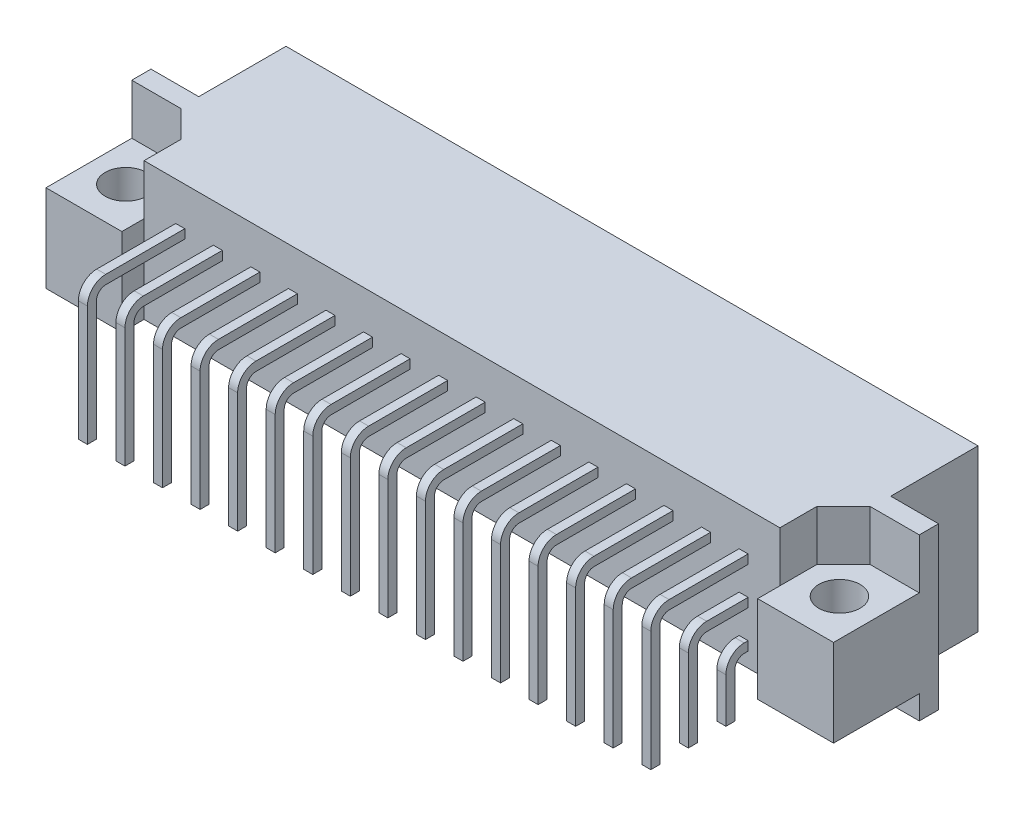
from build123d import *

# Parameters (mm, degrees)
SKETCH_1_W           = 53.26
SKETCH_1_H           = 13
EXTRUDE_1_DEPTH      = 10.9
SKETCH_2_R           = 1.4
CUT_EXTRUDE_1_DEPTH  = 10.9
SKETCH_3_W           = 44.7
SKETCH_3_H           = 8.8
CUT_EXTRUDE_2_DEPTH  = 6.5
SKETCH_5_W           = 0.61
SKETCH_5_H           = 0.61
EXTRUDE_3_DEPTH      = 4.9
SKETCH_4_W           = 0.95
SKETCH_4_H           = 2.8
EXTRUDE_2_DEPTH      = 6.5
SKETCH_6_W           = 3.23
SKETCH_6_H           = 10.9
CUT_EXTRUDE_3_DEPTH  = 5.9
SKETCH_7_W           = 53.26
SKETCH_7_H           = 5.8
CUT_EXTRUDE_4_DEPTH  = 1.6
SKETCH_8_W           = 43
SKETCH_8_H           = 1.5
CUT_EXTRUDE_5_DEPTH  = 11.9
SKETCH_9_R           = 1.4
CUT_EXTRUDE_6_DEPTH  = 3.4
SKETCH_12_W          = 0.61
SKETCH_12_H          = 0.61
EXTRUDE_5_DEPTH      = 1.505
SKETCH_10_W          = 0.61
SKETCH_10_H          = 0.61
EXTRUDE_4_DEPTH      = 1.05
EXTRUDE_4_DEPTH_BACK = 2.61
SKETCH_13_W          = 0.61
SKETCH_13_H          = 0.61
EXTRUDE_6_DEPTH      = 3.145
SKETCH_14_W          = 0.61
SKETCH_14_H          = 0.61
EXTRUDE_7_DEPTH      = 5.685
SKETCH_16_W          = 0.61
SKETCH_16_H          = 0.61
EXTRUDE_8_DEPTH      = 1.93
SKETCH_17_W          = 0.61
SKETCH_17_H          = 0.61
EXTRUDE_9_DEPTH      = 4.5
FILLET_1_R           = 1.24
FILLET_2_R           = 0.64
CHAMFER_1_SIZE       = 0.61


with BuildPart() as part:
    # Эскиз1 → Бобышка-Вытянуть1 (new body)
    with BuildSketch(Plane(origin=(0, 0, 0), x_dir=(1, 0, 0), z_dir=(0, 1, 0))):
        Rectangle(SKETCH_1_W, SKETCH_1_H)
    extrude(amount=EXTRUDE_1_DEPTH)

    # Эскиз2 → Вырез-Вытянуть1 (cut)
    with BuildSketch(Plane(origin=(0, 10.9, 0), x_dir=(1, 0, 0), z_dir=(0, 1, 0))):
        with Locations((24.13, -3.6)):
            Circle(SKETCH_2_R)
        with Locations((-24.13, -3.6)):
            Circle(SKETCH_2_R)
    extrude(amount=-CUT_EXTRUDE_1_DEPTH, mode=Mode.SUBTRACT)

    # Эскиз3 → Вырез-Вытянуть2 (cut)
    with BuildSketch(Plane(origin=(0, 0, -6.5), x_dir=(-1, 0, 0), z_dir=(0, 0, -1))):
        with Locations((0, 5.45)):
            Rectangle(SKETCH_3_W, SKETCH_3_H)
    extrude(amount=-CUT_EXTRUDE_2_DEPTH, mode=Mode.SUBTRACT)

    # Эскиз5 → Бобышка-Вытянуть3 (add)
    with BuildSketch(Plane(origin=(0, 0, 0), x_dir=(-1, 0, 0), z_dir=(0, 0, -1))):
        with Locations((-16.51, 7.99)):
            Rectangle(SKETCH_5_W, SKETCH_5_H)
        with Locations((-19.05, 7.99)):
            Rectangle(SKETCH_5_W, SKETCH_5_H)
        with Locations((-13.97, 7.99)):
            Rectangle(SKETCH_5_W, SKETCH_5_H)
        with Locations((-11.43, 7.99)):
            Rectangle(SKETCH_5_W, SKETCH_5_H)
        with Locations((-8.89, 7.99)):
            Rectangle(SKETCH_5_W, SKETCH_5_H)
        with Locations((-6.35, 7.99)):
            Rectangle(SKETCH_5_W, SKETCH_5_H)
        with Locations((-3.81, 7.99)):
            Rectangle(SKETCH_5_W, SKETCH_5_H)
        with Locations((-1.27, 7.99)):
            Rectangle(SKETCH_5_W, SKETCH_5_H)
        with Locations((1.27, 7.99)):
            Rectangle(SKETCH_5_W, SKETCH_5_H)
        with Locations((3.81, 7.99)):
            Rectangle(SKETCH_5_W, SKETCH_5_H)
        with Locations((6.35, 7.99)):
            Rectangle(SKETCH_5_W, SKETCH_5_H)
        with Locations((8.89, 7.99)):
            Rectangle(SKETCH_5_W, SKETCH_5_H)
        with Locations((11.43, 7.99)):
            Rectangle(SKETCH_5_W, SKETCH_5_H)
        with Locations((13.97, 7.99)):
            Rectangle(SKETCH_5_W, SKETCH_5_H)
        with Locations((16.51, 7.99)):
            Rectangle(SKETCH_5_W, SKETCH_5_H)
        with Locations((19.05, 7.99)):
            Rectangle(SKETCH_5_W, SKETCH_5_H)
        with Locations((-16.51, 5.45)):
            Rectangle(SKETCH_5_W, SKETCH_5_H)
        with Locations((-13.97, 5.45)):
            Rectangle(SKETCH_5_W, SKETCH_5_H)
        with Locations((-11.43, 5.45)):
            Rectangle(SKETCH_5_W, SKETCH_5_H)
        with Locations((-8.89, 5.45)):
            Rectangle(SKETCH_5_W, SKETCH_5_H)
        with Locations((-6.35, 5.45)):
            Rectangle(SKETCH_5_W, SKETCH_5_H)
        with Locations((-3.81, 5.45)):
            Rectangle(SKETCH_5_W, SKETCH_5_H)
        with Locations((-1.27, 5.45)):
            Rectangle(SKETCH_5_W, SKETCH_5_H)
        with Locations((1.27, 5.45)):
            Rectangle(SKETCH_5_W, SKETCH_5_H)
        with Locations((3.81, 5.45)):
            Rectangle(SKETCH_5_W, SKETCH_5_H)
        with Locations((6.35, 5.45)):
            Rectangle(SKETCH_5_W, SKETCH_5_H)
        with Locations((8.89, 5.45)):
            Rectangle(SKETCH_5_W, SKETCH_5_H)
        with Locations((11.43, 5.45)):
            Rectangle(SKETCH_5_W, SKETCH_5_H)
        with Locations((13.97, 5.45)):
            Rectangle(SKETCH_5_W, SKETCH_5_H)
        with Locations((16.51, 5.45)):
            Rectangle(SKETCH_5_W, SKETCH_5_H)
        with Locations((19.05, 5.45)):
            Rectangle(SKETCH_5_W, SKETCH_5_H)
        with Locations((-16.51, 2.91)):
            Rectangle(SKETCH_5_W, SKETCH_5_H)
        with Locations((-13.97, 2.91)):
            Rectangle(SKETCH_5_W, SKETCH_5_H)
        with Locations((-11.43, 2.91)):
            Rectangle(SKETCH_5_W, SKETCH_5_H)
        with Locations((-8.89, 2.91)):
            Rectangle(SKETCH_5_W, SKETCH_5_H)
        with Locations((-6.35, 2.91)):
            Rectangle(SKETCH_5_W, SKETCH_5_H)
        with Locations((-3.81, 2.91)):
            Rectangle(SKETCH_5_W, SKETCH_5_H)
        with Locations((-1.27, 2.91)):
            Rectangle(SKETCH_5_W, SKETCH_5_H)
        with Locations((1.27, 2.91)):
            Rectangle(SKETCH_5_W, SKETCH_5_H)
        with Locations((3.81, 2.91)):
            Rectangle(SKETCH_5_W, SKETCH_5_H)
        with Locations((6.35, 2.91)):
            Rectangle(SKETCH_5_W, SKETCH_5_H)
        with Locations((8.89, 2.91)):
            Rectangle(SKETCH_5_W, SKETCH_5_H)
        with Locations((11.43, 2.91)):
            Rectangle(SKETCH_5_W, SKETCH_5_H)
        with Locations((13.97, 2.91)):
            Rectangle(SKETCH_5_W, SKETCH_5_H)
        with Locations((16.51, 2.91)):
            Rectangle(SKETCH_5_W, SKETCH_5_H)
        with Locations((19.05, 2.91)):
            Rectangle(SKETCH_5_W, SKETCH_5_H)
        with Locations((-19.05, 5.45)):
            Rectangle(SKETCH_5_W, SKETCH_5_H)
        with Locations((-19.05, 2.91)):
            Rectangle(SKETCH_5_W, SKETCH_5_H)
    extrude(amount=EXTRUDE_3_DEPTH)

    # Эскиз4 → Бобышка-Вытянуть2 (add)
    with BuildSketch(Plane(origin=(0, 0, 0), x_dir=(-1, 0, 0), z_dir=(0, 0, -1))):
        with Locations((21.875, 8.45)):
            Rectangle(SKETCH_4_W, SKETCH_4_H)
        with Locations((-21.875, 8.45)):
            Rectangle(SKETCH_4_W, SKETCH_4_H)
    extrude(amount=EXTRUDE_2_DEPTH)

    # Эскиз6 → Вырез-Вытянуть3 (cut)
    with BuildSketch(Plane(origin=(0, 0, -6.5), x_dir=(-1, 0, 0), z_dir=(0, 0, -1))):
        with Locations((25.015, 5.45)):
            Rectangle(SKETCH_6_W, SKETCH_6_H)
        with Locations((-25.015, 5.45)):
            Rectangle(SKETCH_6_W, SKETCH_6_H)
    extrude(amount=-CUT_EXTRUDE_3_DEPTH, mode=Mode.SUBTRACT)

    # Эскиз7 → Вырез-Вытянуть4 (cut)
    with BuildSketch(Plane.XZ):
        with Locations((0, 3.6)):
            Rectangle(SKETCH_7_W, SKETCH_7_H)
    extrude(amount=-CUT_EXTRUDE_4_DEPTH, mode=Mode.SUBTRACT)

    # Эскиз8 → Вырез-Вытянуть5 (cut, through all)
    with BuildSketch(Plane(origin=(0, 10.9, 0), x_dir=(1, 0, 0), z_dir=(0, 1, 0))):
        with Locations((0, -5.75)):
            Rectangle(SKETCH_8_W, SKETCH_8_H)
    extrude(amount=-CUT_EXTRUDE_5_DEPTH, mode=Mode.SUBTRACT)

    # Эскиз9 → Вырез-Вытянуть6 (cut)
    with BuildSketch(Plane(origin=(0, 10.9, 0), x_dir=(1, 0, 0), z_dir=(0, 1, 0))):
        Polygon((-21.5, -2.5), (-23.3, -0.7), (-26.63, -0.7), (-26.63, -6.5), (-21.5, -6.5), (-21.5, -5), align=None)
        with Locations((-24.13, -3.6)):
            Circle(SKETCH_9_R, mode=Mode.SUBTRACT)
        Polygon((21.5, -6.5), (26.63, -6.5), (26.63, -0.7), (23.3, -0.7), (21.5, -2.5), (21.5, -5), align=None)
        with Locations((24.13, -3.6)):
            Circle(SKETCH_9_R, mode=Mode.SUBTRACT)
    extrude(amount=-CUT_EXTRUDE_6_DEPTH, mode=Mode.SUBTRACT)

    # Эскиз12 → Бобышка-Вытянуть5 (add)
    with BuildSketch(Plane.XY.offset(5)):
        with Locations((-16.51, 7.99)):
            Rectangle(SKETCH_12_W, SKETCH_12_H)
        with Locations((-19.05, 7.99)):
            Rectangle(SKETCH_12_W, SKETCH_12_H)
        with Locations((-13.97, 7.99)):
            Rectangle(SKETCH_12_W, SKETCH_12_H)
        with Locations((-11.43, 7.99)):
            Rectangle(SKETCH_12_W, SKETCH_12_H)
        with Locations((-8.89, 7.99)):
            Rectangle(SKETCH_12_W, SKETCH_12_H)
        with Locations((-6.35, 7.99)):
            Rectangle(SKETCH_12_W, SKETCH_12_H)
        with Locations((-3.81, 7.99)):
            Rectangle(SKETCH_12_W, SKETCH_12_H)
        with Locations((-1.27, 7.99)):
            Rectangle(SKETCH_12_W, SKETCH_12_H)
        with Locations((1.27, 7.99)):
            Rectangle(SKETCH_12_W, SKETCH_12_H)
        with Locations((3.81, 7.99)):
            Rectangle(SKETCH_12_W, SKETCH_12_H)
        with Locations((6.35, 7.99)):
            Rectangle(SKETCH_12_W, SKETCH_12_H)
        with Locations((8.89, 7.99)):
            Rectangle(SKETCH_12_W, SKETCH_12_H)
        with Locations((11.43, 7.99)):
            Rectangle(SKETCH_12_W, SKETCH_12_H)
        with Locations((13.97, 7.99)):
            Rectangle(SKETCH_12_W, SKETCH_12_H)
        with Locations((16.51, 7.99)):
            Rectangle(SKETCH_12_W, SKETCH_12_H)
        with Locations((19.05, 7.99)):
            Rectangle(SKETCH_12_W, SKETCH_12_H)
        with Locations((-16.51, 5.45)):
            Rectangle(SKETCH_12_W, SKETCH_12_H)
        with Locations((-13.97, 5.45)):
            Rectangle(SKETCH_12_W, SKETCH_12_H)
        with Locations((-11.43, 5.45)):
            Rectangle(SKETCH_12_W, SKETCH_12_H)
        with Locations((-8.89, 5.45)):
            Rectangle(SKETCH_12_W, SKETCH_12_H)
        with Locations((-6.35, 5.45)):
            Rectangle(SKETCH_12_W, SKETCH_12_H)
        with Locations((-3.81, 5.45)):
            Rectangle(SKETCH_12_W, SKETCH_12_H)
        with Locations((-1.27, 5.45)):
            Rectangle(SKETCH_12_W, SKETCH_12_H)
        with Locations((1.27, 5.45)):
            Rectangle(SKETCH_12_W, SKETCH_12_H)
        with Locations((3.81, 5.45)):
            Rectangle(SKETCH_12_W, SKETCH_12_H)
        with Locations((6.35, 5.45)):
            Rectangle(SKETCH_12_W, SKETCH_12_H)
        with Locations((8.89, 5.45)):
            Rectangle(SKETCH_12_W, SKETCH_12_H)
        with Locations((11.43, 5.45)):
            Rectangle(SKETCH_12_W, SKETCH_12_H)
        with Locations((13.97, 5.45)):
            Rectangle(SKETCH_12_W, SKETCH_12_H)
        with Locations((16.51, 5.45)):
            Rectangle(SKETCH_12_W, SKETCH_12_H)
        with Locations((19.05, 5.45)):
            Rectangle(SKETCH_12_W, SKETCH_12_H)
        with Locations((-16.51, 2.91)):
            Rectangle(SKETCH_12_W, SKETCH_12_H)
        with Locations((-13.97, 2.91)):
            Rectangle(SKETCH_12_W, SKETCH_12_H)
        with Locations((-11.43, 2.91)):
            Rectangle(SKETCH_12_W, SKETCH_12_H)
        with Locations((-8.89, 2.91)):
            Rectangle(SKETCH_12_W, SKETCH_12_H)
        with Locations((-6.35, 2.91)):
            Rectangle(SKETCH_12_W, SKETCH_12_H)
        with Locations((-3.81, 2.91)):
            Rectangle(SKETCH_12_W, SKETCH_12_H)
        with Locations((-1.27, 2.91)):
            Rectangle(SKETCH_12_W, SKETCH_12_H)
        with Locations((1.27, 2.91)):
            Rectangle(SKETCH_12_W, SKETCH_12_H)
        with Locations((3.81, 2.91)):
            Rectangle(SKETCH_12_W, SKETCH_12_H)
        with Locations((6.35, 2.91)):
            Rectangle(SKETCH_12_W, SKETCH_12_H)
        with Locations((8.89, 2.91)):
            Rectangle(SKETCH_12_W, SKETCH_12_H)
        with Locations((11.43, 2.91)):
            Rectangle(SKETCH_12_W, SKETCH_12_H)
        with Locations((13.97, 2.91)):
            Rectangle(SKETCH_12_W, SKETCH_12_H)
        with Locations((16.51, 2.91)):
            Rectangle(SKETCH_12_W, SKETCH_12_H)
        with Locations((19.05, 2.91)):
            Rectangle(SKETCH_12_W, SKETCH_12_H)
        with Locations((-19.05, 5.45)):
            Rectangle(SKETCH_12_W, SKETCH_12_H)
        with Locations((-19.05, 2.91)):
            Rectangle(SKETCH_12_W, SKETCH_12_H)
    extrude(amount=EXTRUDE_5_DEPTH)

    # Эскиз10 → Бобышка-Вытянуть4 (add, two sides)
    with BuildSketch(Plane.XZ) as extrude_4_sk:
        with Locations((-16.51, 6.2)):
            Rectangle(SKETCH_10_W, SKETCH_10_H)
        with Locations((-19.05, 6.2)):
            Rectangle(SKETCH_10_W, SKETCH_10_H)
        with Locations((-13.97, 6.2)):
            Rectangle(SKETCH_10_W, SKETCH_10_H)
        with Locations((-11.43, 6.2)):
            Rectangle(SKETCH_10_W, SKETCH_10_H)
        with Locations((-8.89, 6.2)):
            Rectangle(SKETCH_10_W, SKETCH_10_H)
        with Locations((-6.35, 6.2)):
            Rectangle(SKETCH_10_W, SKETCH_10_H)
        with Locations((-3.81, 6.2)):
            Rectangle(SKETCH_10_W, SKETCH_10_H)
        with Locations((-1.27, 6.2)):
            Rectangle(SKETCH_10_W, SKETCH_10_H)
        with Locations((1.27, 6.2)):
            Rectangle(SKETCH_10_W, SKETCH_10_H)
        with Locations((3.81, 6.2)):
            Rectangle(SKETCH_10_W, SKETCH_10_H)
        with Locations((6.35, 6.2)):
            Rectangle(SKETCH_10_W, SKETCH_10_H)
        with Locations((8.89, 6.2)):
            Rectangle(SKETCH_10_W, SKETCH_10_H)
        with Locations((11.43, 6.2)):
            Rectangle(SKETCH_10_W, SKETCH_10_H)
        with Locations((13.97, 6.2)):
            Rectangle(SKETCH_10_W, SKETCH_10_H)
        with Locations((16.51, 6.2)):
            Rectangle(SKETCH_10_W, SKETCH_10_H)
        with Locations((19.05, 6.2)):
            Rectangle(SKETCH_10_W, SKETCH_10_H)
        with Locations((-16.51, 8.74)):
            Rectangle(SKETCH_10_W, SKETCH_10_H)
        with Locations((-13.97, 8.74)):
            Rectangle(SKETCH_10_W, SKETCH_10_H)
        with Locations((-11.43, 8.74)):
            Rectangle(SKETCH_10_W, SKETCH_10_H)
        with Locations((-8.89, 8.74)):
            Rectangle(SKETCH_10_W, SKETCH_10_H)
        with Locations((-6.35, 8.74)):
            Rectangle(SKETCH_10_W, SKETCH_10_H)
        with Locations((-3.81, 8.74)):
            Rectangle(SKETCH_10_W, SKETCH_10_H)
        with Locations((-1.27, 8.74)):
            Rectangle(SKETCH_10_W, SKETCH_10_H)
        with Locations((1.27, 8.74)):
            Rectangle(SKETCH_10_W, SKETCH_10_H)
        with Locations((3.81, 8.74)):
            Rectangle(SKETCH_10_W, SKETCH_10_H)
        with Locations((6.35, 8.74)):
            Rectangle(SKETCH_10_W, SKETCH_10_H)
        with Locations((8.89, 8.74)):
            Rectangle(SKETCH_10_W, SKETCH_10_H)
        with Locations((11.43, 8.74)):
            Rectangle(SKETCH_10_W, SKETCH_10_H)
        with Locations((13.97, 8.74)):
            Rectangle(SKETCH_10_W, SKETCH_10_H)
        with Locations((16.51, 8.74)):
            Rectangle(SKETCH_10_W, SKETCH_10_H)
        with Locations((19.05, 8.74)):
            Rectangle(SKETCH_10_W, SKETCH_10_H)
        with Locations((-16.51, 11.28)):
            Rectangle(SKETCH_10_W, SKETCH_10_H)
        with Locations((-13.97, 11.28)):
            Rectangle(SKETCH_10_W, SKETCH_10_H)
        with Locations((-11.43, 11.28)):
            Rectangle(SKETCH_10_W, SKETCH_10_H)
        with Locations((-8.89, 11.28)):
            Rectangle(SKETCH_10_W, SKETCH_10_H)
        with Locations((-6.35, 11.28)):
            Rectangle(SKETCH_10_W, SKETCH_10_H)
        with Locations((-3.81, 11.28)):
            Rectangle(SKETCH_10_W, SKETCH_10_H)
        with Locations((-1.27, 11.28)):
            Rectangle(SKETCH_10_W, SKETCH_10_H)
        with Locations((1.27, 11.28)):
            Rectangle(SKETCH_10_W, SKETCH_10_H)
        with Locations((3.81, 11.28)):
            Rectangle(SKETCH_10_W, SKETCH_10_H)
        with Locations((6.35, 11.28)):
            Rectangle(SKETCH_10_W, SKETCH_10_H)
        with Locations((8.89, 11.28)):
            Rectangle(SKETCH_10_W, SKETCH_10_H)
        with Locations((11.43, 11.28)):
            Rectangle(SKETCH_10_W, SKETCH_10_H)
        with Locations((13.97, 11.28)):
            Rectangle(SKETCH_10_W, SKETCH_10_H)
        with Locations((16.51, 11.28)):
            Rectangle(SKETCH_10_W, SKETCH_10_H)
        with Locations((19.05, 11.28)):
            Rectangle(SKETCH_10_W, SKETCH_10_H)
        with Locations((-19.05, 8.74)):
            Rectangle(SKETCH_10_W, SKETCH_10_H)
        with Locations((-19.05, 11.28)):
            Rectangle(SKETCH_10_W, SKETCH_10_H)
    extrude(amount=EXTRUDE_4_DEPTH)
    extrude(extrude_4_sk.sketch, amount=-EXTRUDE_4_DEPTH_BACK)

    # Эскиз13 → Бобышка-Вытянуть6 (add)
    with BuildSketch(Plane(origin=(0, 2.61, 0), x_dir=(1, 0, 0), z_dir=(0, 1, 0))):
        with Locations((19.05, -8.74)):
            Rectangle(SKETCH_13_W, SKETCH_13_H)
        with Locations((16.51, -8.74)):
            Rectangle(SKETCH_13_W, SKETCH_13_H)
        with Locations((13.97, -8.74)):
            Rectangle(SKETCH_13_W, SKETCH_13_H)
        with Locations((11.43, -8.74)):
            Rectangle(SKETCH_13_W, SKETCH_13_H)
        with Locations((8.89, -8.74)):
            Rectangle(SKETCH_13_W, SKETCH_13_H)
        with Locations((6.35, -8.74)):
            Rectangle(SKETCH_13_W, SKETCH_13_H)
        with Locations((3.81, -8.74)):
            Rectangle(SKETCH_13_W, SKETCH_13_H)
        with Locations((1.27, -8.74)):
            Rectangle(SKETCH_13_W, SKETCH_13_H)
        with Locations((-1.27, -8.74)):
            Rectangle(SKETCH_13_W, SKETCH_13_H)
        with Locations((-3.81, -8.74)):
            Rectangle(SKETCH_13_W, SKETCH_13_H)
        with Locations((-6.35, -8.74)):
            Rectangle(SKETCH_13_W, SKETCH_13_H)
        with Locations((-8.89, -8.74)):
            Rectangle(SKETCH_13_W, SKETCH_13_H)
        with Locations((-11.43, -8.74)):
            Rectangle(SKETCH_13_W, SKETCH_13_H)
        with Locations((-13.97, -8.74)):
            Rectangle(SKETCH_13_W, SKETCH_13_H)
        with Locations((-16.51, -8.74)):
            Rectangle(SKETCH_13_W, SKETCH_13_H)
        with Locations((-19.05, -8.74)):
            Rectangle(SKETCH_13_W, SKETCH_13_H)
    extrude(amount=EXTRUDE_6_DEPTH)

    # Эскиз14 → Бобышка-Вытянуть7 (add)
    with BuildSketch(Plane(origin=(0, 2.61, 0), x_dir=(1, 0, 0), z_dir=(0, 1, 0))):
        with Locations((19.05, -11.28)):
            Rectangle(SKETCH_14_W, SKETCH_14_H)
        with Locations((16.51, -11.28)):
            Rectangle(SKETCH_14_W, SKETCH_14_H)
        with Locations((13.97, -11.28)):
            Rectangle(SKETCH_14_W, SKETCH_14_H)
        with Locations((11.43, -11.28)):
            Rectangle(SKETCH_14_W, SKETCH_14_H)
        with Locations((8.89, -11.28)):
            Rectangle(SKETCH_14_W, SKETCH_14_H)
        with Locations((6.35, -11.28)):
            Rectangle(SKETCH_14_W, SKETCH_14_H)
        with Locations((3.81, -11.28)):
            Rectangle(SKETCH_14_W, SKETCH_14_H)
        with Locations((1.27, -11.28)):
            Rectangle(SKETCH_14_W, SKETCH_14_H)
        with Locations((-1.27, -11.28)):
            Rectangle(SKETCH_14_W, SKETCH_14_H)
        with Locations((-3.81, -11.28)):
            Rectangle(SKETCH_14_W, SKETCH_14_H)
        with Locations((-6.35, -11.28)):
            Rectangle(SKETCH_14_W, SKETCH_14_H)
        with Locations((-8.89, -11.28)):
            Rectangle(SKETCH_14_W, SKETCH_14_H)
        with Locations((-11.43, -11.28)):
            Rectangle(SKETCH_14_W, SKETCH_14_H)
        with Locations((-13.97, -11.28)):
            Rectangle(SKETCH_14_W, SKETCH_14_H)
        with Locations((-16.51, -11.28)):
            Rectangle(SKETCH_14_W, SKETCH_14_H)
        with Locations((-19.05, -11.28)):
            Rectangle(SKETCH_14_W, SKETCH_14_H)
    extrude(amount=EXTRUDE_7_DEPTH)

    # Эскиз16 → Бобышка-Вытянуть8 (add)
    with BuildSketch(Plane.XY.offset(6.505)):
        with Locations((19.05, 5.45)):
            Rectangle(SKETCH_16_W, SKETCH_16_H)
        with Locations((16.51, 5.45)):
            Rectangle(SKETCH_16_W, SKETCH_16_H)
        with Locations((13.97, 5.45)):
            Rectangle(SKETCH_16_W, SKETCH_16_H)
        with Locations((11.43, 5.45)):
            Rectangle(SKETCH_16_W, SKETCH_16_H)
        with Locations((8.89, 5.45)):
            Rectangle(SKETCH_16_W, SKETCH_16_H)
        with Locations((6.35, 5.45)):
            Rectangle(SKETCH_16_W, SKETCH_16_H)
        with Locations((3.81, 5.45)):
            Rectangle(SKETCH_16_W, SKETCH_16_H)
        with Locations((1.27, 5.45)):
            Rectangle(SKETCH_16_W, SKETCH_16_H)
        with Locations((-1.27, 5.45)):
            Rectangle(SKETCH_16_W, SKETCH_16_H)
        with Locations((-3.81, 5.45)):
            Rectangle(SKETCH_16_W, SKETCH_16_H)
        with Locations((-6.35, 5.45)):
            Rectangle(SKETCH_16_W, SKETCH_16_H)
        with Locations((-8.89, 5.45)):
            Rectangle(SKETCH_16_W, SKETCH_16_H)
        with Locations((-11.43, 5.45)):
            Rectangle(SKETCH_16_W, SKETCH_16_H)
        with Locations((-13.97, 5.45)):
            Rectangle(SKETCH_16_W, SKETCH_16_H)
        with Locations((-16.51, 5.45)):
            Rectangle(SKETCH_16_W, SKETCH_16_H)
        with Locations((-19.05, 5.45)):
            Rectangle(SKETCH_16_W, SKETCH_16_H)
    extrude(amount=EXTRUDE_8_DEPTH)

    # Эскиз17 → Бобышка-Вытянуть9 (add)
    with BuildSketch(Plane.XY.offset(6.505)):
        with Locations((19.05, 7.99)):
            Rectangle(SKETCH_17_W, SKETCH_17_H)
        with Locations((16.51, 7.99)):
            Rectangle(SKETCH_17_W, SKETCH_17_H)
        with Locations((13.97, 7.99)):
            Rectangle(SKETCH_17_W, SKETCH_17_H)
        with Locations((11.43, 7.99)):
            Rectangle(SKETCH_17_W, SKETCH_17_H)
        with Locations((8.89, 7.99)):
            Rectangle(SKETCH_17_W, SKETCH_17_H)
        with Locations((6.35, 7.99)):
            Rectangle(SKETCH_17_W, SKETCH_17_H)
        with Locations((3.81, 7.99)):
            Rectangle(SKETCH_17_W, SKETCH_17_H)
        with Locations((1.27, 7.99)):
            Rectangle(SKETCH_17_W, SKETCH_17_H)
        with Locations((-1.27, 7.99)):
            Rectangle(SKETCH_17_W, SKETCH_17_H)
        with Locations((-3.81, 7.99)):
            Rectangle(SKETCH_17_W, SKETCH_17_H)
        with Locations((-6.35, 7.99)):
            Rectangle(SKETCH_17_W, SKETCH_17_H)
        with Locations((-8.89, 7.99)):
            Rectangle(SKETCH_17_W, SKETCH_17_H)
        with Locations((-11.43, 7.99)):
            Rectangle(SKETCH_17_W, SKETCH_17_H)
        with Locations((-13.97, 7.99)):
            Rectangle(SKETCH_17_W, SKETCH_17_H)
        with Locations((-16.51, 7.99)):
            Rectangle(SKETCH_17_W, SKETCH_17_H)
        with Locations((-19.05, 7.99)):
            Rectangle(SKETCH_17_W, SKETCH_17_H)
    extrude(amount=EXTRUDE_9_DEPTH)

    # Скругление1
    fillet_1_edges = [part.edges().sort_by_distance(p)[0] for p in [
        (6.35, 8.295, 11.585),
        (3.81, 8.295, 11.585),
        (1.27, 8.295, 11.585),
        (-1.27, 8.295, 11.585),
        (-3.81, 8.295, 11.585),
        (-6.35, 8.295, 11.585),
        (-8.89, 8.295, 11.585),
        (-11.43, 8.295, 11.585),
        (-13.97, 8.295, 11.585),
        (-19.05, 8.295, 11.585),
        (-16.51, 5.755, 9.045),
        (-13.97, 5.755, 9.045),
        (-11.43, 5.755, 9.045),
        (-16.51, 8.295, 11.585),
        (-8.89, 5.755, 9.045),
        (-6.35, 5.755, 9.045),
        (-3.81, 5.755, 9.045),
        (-1.27, 5.755, 9.045),
        (1.27, 5.755, 9.045),
        (3.81, 5.755, 9.045),
        (6.35, 5.755, 9.045),
        (8.89, 5.755, 9.045),
        (11.43, 5.755, 9.045),
        (13.97, 5.755, 9.045),
        (16.51, 5.755, 9.045),
        (19.05, 5.755, 9.045),
        (-16.51, 3.215, 6.505),
        (-13.97, 3.215, 6.505),
        (-11.43, 3.215, 6.505),
        (-8.89, 3.215, 6.505),
        (-6.35, 3.215, 6.505),
        (-3.81, 3.215, 6.505),
        (-1.27, 3.215, 6.505),
        (1.27, 3.215, 6.505),
        (3.81, 3.215, 6.505),
        (6.35, 3.215, 6.505),
        (8.89, 3.215, 6.505),
        (11.43, 3.215, 6.505),
        (13.97, 3.215, 6.505),
        (16.51, 3.215, 6.505),
        (19.05, 3.215, 6.505),
        (-19.05, 5.755, 9.045),
        (-19.05, 3.215, 6.505),
        (19.05, 8.295, 11.585),
        (16.51, 8.295, 11.585),
        (13.97, 8.295, 11.585),
        (11.43, 8.295, 11.585),
        (8.89, 8.295, 11.585),
    ]]
    fillet(fillet_1_edges, radius=FILLET_1_R)

    # Скругление2
    fillet_2_edges = [part.edges().sort_by_distance(p)[0] for p in [
        (6.35, 7.685, 10.975),
        (3.81, 7.685, 10.975),
        (1.27, 7.685, 10.975),
        (-1.27, 7.685, 10.975),
        (-3.81, 7.685, 10.975),
        (-6.35, 7.685, 10.975),
        (-8.89, 7.685, 10.975),
        (-11.43, 7.685, 10.975),
        (-13.97, 7.685, 10.975),
        (-19.05, 7.685, 10.975),
        (-16.51, 2.605, 5.895),
        (-13.97, 2.605, 5.895),
        (-11.43, 2.605, 5.895),
        (-8.89, 2.605, 5.895),
        (-6.35, 2.605, 5.895),
        (-3.81, 2.605, 5.895),
        (-1.27, 2.605, 5.895),
        (1.27, 2.605, 5.895),
        (3.81, 2.605, 5.895),
        (6.35, 2.605, 5.895),
        (8.89, 2.605, 5.895),
        (11.43, 2.605, 5.895),
        (13.97, 2.605, 5.895),
        (16.51, 2.605, 5.895),
        (19.05, 2.605, 5.895),
        (-19.05, 2.605, 5.895),
        (19.05, 5.145, 8.435),
        (16.51, 5.145, 8.435),
        (13.97, 5.145, 8.435),
        (11.43, 5.145, 8.435),
        (8.89, 5.145, 8.435),
        (6.35, 5.145, 8.435),
        (3.81, 5.145, 8.435),
        (1.27, 5.145, 8.435),
        (-1.27, 5.145, 8.435),
        (-3.81, 5.145, 8.435),
        (-6.35, 5.145, 8.435),
        (-8.89, 5.145, 8.435),
        (-11.43, 5.145, 8.435),
        (-13.97, 5.145, 8.435),
        (-16.51, 5.145, 8.435),
        (-19.05, 5.145, 8.435),
        (-16.51, 7.685, 10.975),
        (19.05, 7.685, 10.975),
        (16.51, 7.685, 10.975),
        (13.97, 7.685, 10.975),
        (11.43, 7.685, 10.975),
        (8.89, 7.685, 10.975),
    ]]
    fillet(fillet_2_edges, radius=FILLET_2_R)

    # Фаска1
    chamfer_1_edges = [part.edges().sort_by_distance(p)[0] for p in [
        (0, 9.85, -6.5),
        (22.35, 4.05, -6.5),
        (-22.35, 4.05, -6.5),
        (-21.4, 8.45, -6.5),
        (-21.875, 7.05, -6.5),
        (21.875, 7.05, -6.5),
        (21.4, 8.45, -6.5),
        (0, 1.05, -6.5),
    ]]
    chamfer(chamfer_1_edges, length=CHAMFER_1_SIZE)


solid = part.part
